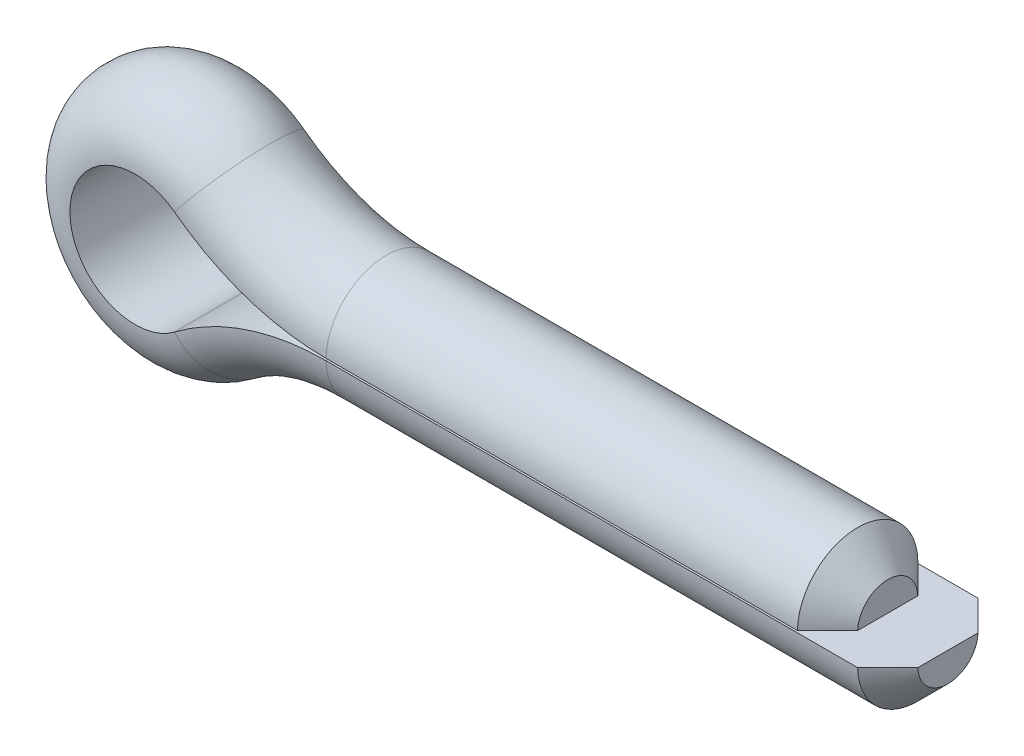
from build123d import *

# Parameters (mm, degrees)
CHAMFER1_SIZE = 0.762


with BuildPart() as part:
    # Sweep1: sweep along a path in Sketch3
    with BuildLine(Plane.XY) as sweep1_path:
        Line((1.524, -0.0254), (-12.7, -0.0254))
        ThreePointArc((-12.7, -0.0254), (-14.723920445, -0.356575694), (-16.536731203, -1.31555873))
        ThreePointArc((-16.536731203, -1.31555873), (-19.185281316, 0), (-16.536731203, 1.31555873))
        ThreePointArc((-16.536731203, 1.31555873), (-14.723920445, 0.356575694), (-12.7, 0.0254))
        Line((-12.7, 0.0254), (0, 0.0254))
    # Sketch4 → Sweep1 (sweep)
    with BuildSketch(Plane(origin=(0, 0, 0), x_dir=(0, 0, -1), z_dir=(1, 0, 0))):
        with BuildLine():
            Line((-1.523788319, 0.0254), (1.523788319, 0.0254))
            ThreePointArc((1.523788319, 0.0254), (0, 1.524), (-1.523788319, 0.0254))
        make_face()
    sweep(path=sweep1_path.line)

    # Chamfer1
    chamfer1_edges = [part.edges().sort_by_distance(p)[0] for p in [
        (0, 1.524, 0),
        (1.524, -1.524, 0),
    ]]
    chamfer(chamfer1_edges, length=CHAMFER1_SIZE)


solid = part.part
